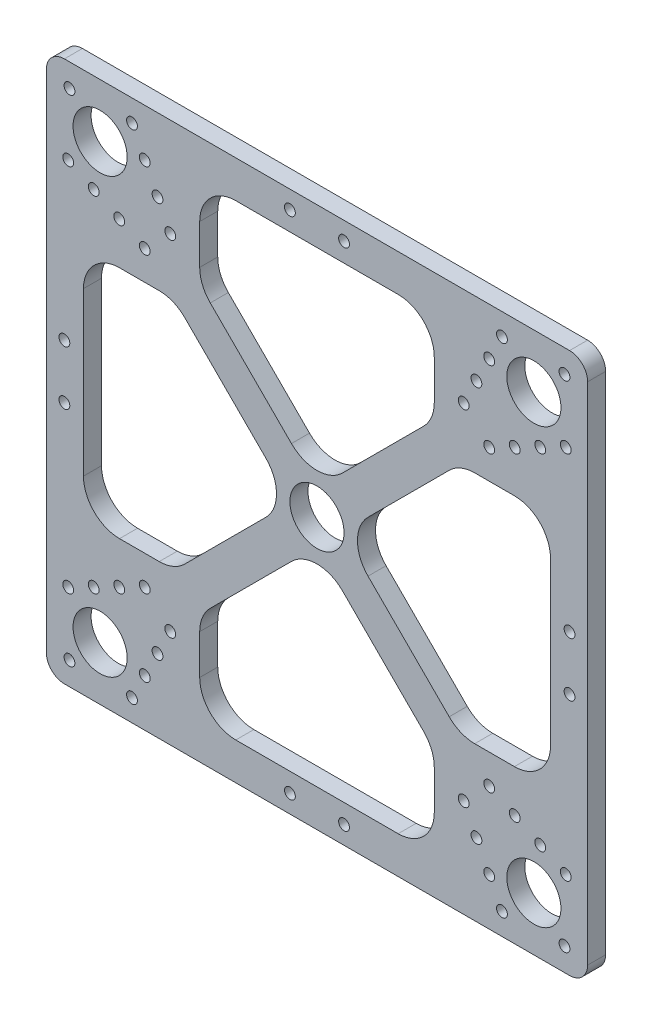
from build123d import *

# Parameters (mm, degrees)
SKETCH1_R           = 7.5
SKETCH1_R_2         = 1.5
BOSS_EXTRUDE1_DEPTH = 5


with BuildPart() as part:
    # Sketch1 → Boss-Extrude1 (new body)
    with BuildSketch(Plane.XY):
        with BuildLine():
            Line((70, 75), (-70, 75))
            ThreePointArc((-70, 75), (-73.535533906, 73.535533906), (-75, 70))
            Line((-75, 70), (-75, -70))
            ThreePointArc((-75, -70), (-73.535533906, -73.535533906), (-70, -75))
            Line((-70, -75), (70, -75))
            ThreePointArc((70, -75), (73.535533906, -73.535533906), (75, -70))
            Line((75, -70), (75, 70))
            ThreePointArc((75, 70), (73.535533906, 73.535533906), (70, 75))
        make_face()
        with Locations((-60.104076401, 60.104076401)):
            Circle(SKETCH1_R, mode=Mode.SUBTRACT)
        with Locations((60.104076401, 60.104076401)):
            Circle(SKETCH1_R, mode=Mode.SUBTRACT)
        with Locations((60.104076401, -60.104076401)):
            Circle(SKETCH1_R, mode=Mode.SUBTRACT)
        with Locations((-60.104076401, -60.104076401)):
            Circle(SKETCH1_R, mode=Mode.SUBTRACT)
        Circle(SKETCH1_R, mode=Mode.SUBTRACT)
        with Locations((-7.5, 70)):
            Circle(SKETCH1_R_2, mode=Mode.SUBTRACT)
        with Locations((7.5, 70)):
            Circle(SKETCH1_R_2, mode=Mode.SUBTRACT)
        with Locations((70, 7.5)):
            Circle(SKETCH1_R_2, mode=Mode.SUBTRACT)
        with Locations((70, -7.5)):
            Circle(SKETCH1_R_2, mode=Mode.SUBTRACT)
        with Locations((7.5, -70)):
            Circle(SKETCH1_R_2, mode=Mode.SUBTRACT)
        with Locations((-7.5, -70)):
            Circle(SKETCH1_R_2, mode=Mode.SUBTRACT)
        with Locations((-70, -7.5)):
            Circle(SKETCH1_R_2, mode=Mode.SUBTRACT)
        with Locations((-70, 7.5)):
            Circle(SKETCH1_R_2, mode=Mode.SUBTRACT)
        with Locations((40.658639918, 47.72970773)):
            Circle(SKETCH1_R_2, mode=Mode.SUBTRACT)
        with Locations((47.72970773, 40.658639918)):
            Circle(SKETCH1_R_2, mode=Mode.SUBTRACT)
        with Locations((44.194173824, 54.800775542)):
            Circle(SKETCH1_R_2, mode=Mode.SUBTRACT)
        with Locations((54.800775542, 44.194173824)):
            Circle(SKETCH1_R_2, mode=Mode.SUBTRACT)
        with Locations((61.871843354, 47.72970773)):
            Circle(SKETCH1_R_2, mode=Mode.SUBTRACT)
        with Locations((47.72970773, 61.871843354)):
            Circle(SKETCH1_R_2, mode=Mode.SUBTRACT)
        with Locations((51.265241636, 68.942911166)):
            Circle(SKETCH1_R_2, mode=Mode.SUBTRACT)
        with Locations((68.942911166, 51.265241636)):
            Circle(SKETCH1_R_2, mode=Mode.SUBTRACT)
        with Locations((47.72970773, -40.658639918)):
            Circle(SKETCH1_R_2, mode=Mode.SUBTRACT)
        with Locations((54.800775542, -44.194173824)):
            Circle(SKETCH1_R_2, mode=Mode.SUBTRACT)
        with Locations((61.871843354, -47.72970773)):
            Circle(SKETCH1_R_2, mode=Mode.SUBTRACT)
        with Locations((68.942911166, -51.265241636)):
            Circle(SKETCH1_R_2, mode=Mode.SUBTRACT)
        with Locations((51.265241636, -68.942911166)):
            Circle(SKETCH1_R_2, mode=Mode.SUBTRACT)
        with Locations((47.72970773, -61.871843354)):
            Circle(SKETCH1_R_2, mode=Mode.SUBTRACT)
        with Locations((44.194173824, -54.800775542)):
            Circle(SKETCH1_R_2, mode=Mode.SUBTRACT)
        with Locations((40.658639918, -47.72970773)):
            Circle(SKETCH1_R_2, mode=Mode.SUBTRACT)
        with Locations((-40.658639918, -47.72970773)):
            Circle(SKETCH1_R_2, mode=Mode.SUBTRACT)
        with Locations((-44.194173824, -54.800775542)):
            Circle(SKETCH1_R_2, mode=Mode.SUBTRACT)
        with Locations((-47.72970773, -61.871843354)):
            Circle(SKETCH1_R_2, mode=Mode.SUBTRACT)
        with Locations((-51.265241636, -68.942911166)):
            Circle(SKETCH1_R_2, mode=Mode.SUBTRACT)
        with Locations((-68.942911166, -51.265241636)):
            Circle(SKETCH1_R_2, mode=Mode.SUBTRACT)
        with Locations((-61.871843354, -47.72970773)):
            Circle(SKETCH1_R_2, mode=Mode.SUBTRACT)
        with Locations((-54.800775542, -44.194173824)):
            Circle(SKETCH1_R_2, mode=Mode.SUBTRACT)
        with Locations((-47.72970773, -40.658639918)):
            Circle(SKETCH1_R_2, mode=Mode.SUBTRACT)
        with Locations((-47.72970773, 40.658639918)):
            Circle(SKETCH1_R_2, mode=Mode.SUBTRACT)
        with Locations((-54.800775542, 44.194173824)):
            Circle(SKETCH1_R_2, mode=Mode.SUBTRACT)
        with Locations((-61.871843354, 47.72970773)):
            Circle(SKETCH1_R_2, mode=Mode.SUBTRACT)
        with Locations((-68.942911166, 51.265241636)):
            Circle(SKETCH1_R_2, mode=Mode.SUBTRACT)
        with Locations((-51.265241636, 68.942911166)):
            Circle(SKETCH1_R_2, mode=Mode.SUBTRACT)
        with Locations((-47.72970773, 61.871843354)):
            Circle(SKETCH1_R_2, mode=Mode.SUBTRACT)
        with Locations((-44.194173824, 54.800775542)):
            Circle(SKETCH1_R_2, mode=Mode.SUBTRACT)
        with Locations((-40.658639918, 47.72970773)):
            Circle(SKETCH1_R_2, mode=Mode.SUBTRACT)
        with Locations((68.589357775, 68.589357775)):
            Circle(SKETCH1_R_2, mode=Mode.SUBTRACT)
        with Locations((68.589357775, -68.589357775)):
            Circle(SKETCH1_R_2, mode=Mode.SUBTRACT)
        with Locations((-68.589357775, -68.589357775)):
            Circle(SKETCH1_R_2, mode=Mode.SUBTRACT)
        with Locations((-68.589357775, 68.589357775)):
            Circle(SKETCH1_R_2, mode=Mode.SUBTRACT)
        with BuildLine():
            Line((14.142135624, 7.071067812), (36.642135624, 29.571067812))
            ThreePointArc((36.642135624, 29.571067812), (39.886369112, 31.738795325), (43.713203436, 32.5))
            Line((43.713203436, 32.5), (54.713203436, 32.5))
            ThreePointArc((54.713203436, 32.5), (61.784271247, 29.571067812), (64.713203436, 22.5))
            Line((64.713203436, 22.5), (64.713203436, -22.5))
            ThreePointArc((64.713203436, -22.5), (61.784271247, -29.571067812), (54.713203436, -32.5))
            Line((54.713203436, -32.5), (43.713203436, -32.5))
            ThreePointArc((43.713203436, -32.5), (39.886369112, -31.738795325), (36.642135624, -29.571067812))
            Line((36.642135624, -29.571067812), (14.142135624, -7.071067812))
            ThreePointArc((14.142135624, -7.071067812), (11.213203436, 0), (14.142135624, 7.071067812))
        make_face(mode=Mode.SUBTRACT)
        with BuildLine():
            Line((-22.5, 64.713203436), (22.5, 64.713203436))
            ThreePointArc((22.5, 64.713203436), (29.571067812, 61.784271247), (32.5, 54.713203436))
            Line((32.5, 54.713203436), (32.5, 43.713203436))
            ThreePointArc((32.5, 43.713203436), (31.738795325, 39.886369112), (29.571067812, 36.642135624))
            Line((29.571067812, 36.642135624), (7.071067812, 14.142135624))
            ThreePointArc((7.071067812, 14.142135624), (0, 11.213203436), (-7.071067812, 14.142135624))
            Line((-7.071067812, 14.142135624), (-29.571067812, 36.642135624))
            ThreePointArc((-29.571067812, 36.642135624), (-31.738795325, 39.886369112), (-32.5, 43.713203436))
            Line((-32.5, 43.713203436), (-32.5, 54.713203436))
            ThreePointArc((-32.5, 54.713203436), (-29.571067812, 61.784271247), (-22.5, 64.713203436))
        make_face(mode=Mode.SUBTRACT)
        with BuildLine():
            Line((7.071067812, -14.142135624), (29.571067812, -36.642135624))
            ThreePointArc((29.571067812, -36.642135624), (31.738795325, -39.886369112), (32.5, -43.713203436))
            Line((32.5, -43.713203436), (32.5, -54.713203436))
            ThreePointArc((32.5, -54.713203436), (29.571067812, -61.784271247), (22.5, -64.713203436))
            Line((22.5, -64.713203436), (-22.5, -64.713203436))
            ThreePointArc((-22.5, -64.713203436), (-29.571067812, -61.784271247), (-32.5, -54.713203436))
            Line((-32.5, -54.713203436), (-32.5, -43.713203436))
            ThreePointArc((-32.5, -43.713203436), (-31.738795325, -39.886369112), (-29.571067812, -36.642135624))
            Line((-29.571067812, -36.642135624), (-7.071067812, -14.142135624))
            ThreePointArc((-7.071067812, -14.142135624), (0, -11.213203436), (7.071067812, -14.142135624))
        make_face(mode=Mode.SUBTRACT)
        with BuildLine():
            Line((-14.142135624, -7.071067812), (-36.642135624, -29.571067812))
            ThreePointArc((-36.642135624, -29.571067812), (-39.886369112, -31.738795325), (-43.713203436, -32.5))
            Line((-43.713203436, -32.5), (-54.713203436, -32.5))
            ThreePointArc((-54.713203436, -32.5), (-61.784271247, -29.571067812), (-64.713203436, -22.5))
            Line((-64.713203436, -22.5), (-64.713203436, 22.5))
            ThreePointArc((-64.713203436, 22.5), (-61.784271247, 29.571067812), (-54.713203436, 32.5))
            Line((-54.713203436, 32.5), (-43.713203436, 32.5))
            ThreePointArc((-43.713203436, 32.5), (-39.886369112, 31.738795325), (-36.642135624, 29.571067812))
            Line((-36.642135624, 29.571067812), (-14.142135624, 7.071067812))
            ThreePointArc((-14.142135624, 7.071067812), (-11.213203436, 0), (-14.142135624, -7.071067812))
        make_face(mode=Mode.SUBTRACT)
    extrude(amount=BOSS_EXTRUDE1_DEPTH)


solid = part.part
